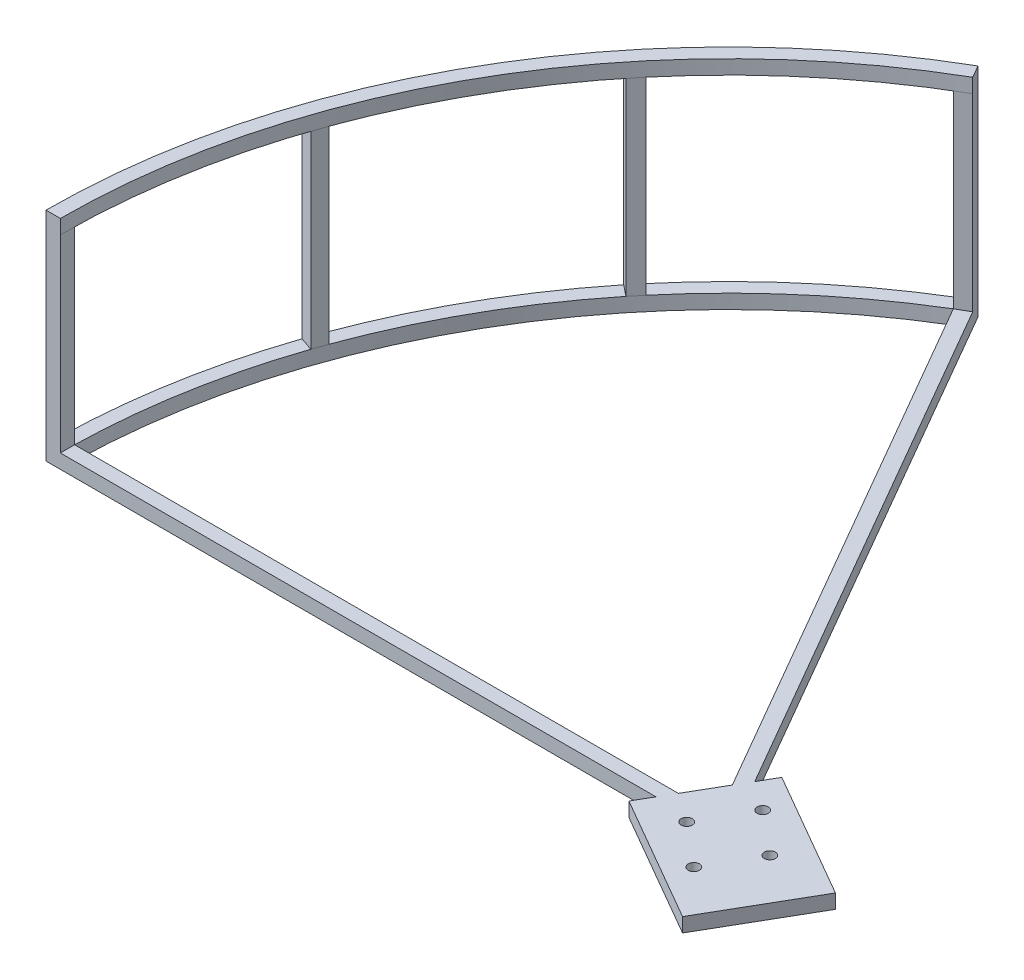
from build123d import *

# Parameters (mm, degrees)
SKETCH1_R           = 1.25
BOSS_EXTRUDE1_DEPTH = 3.175
BOSS_EXTRUDE2_DEPTH = 3.175
BOSS_EXTRUDE3_DEPTH = 42.2
BOSS_EXTRUDE4_DEPTH = 3.175


with BuildPart() as part:
    # Sketch1 → Boss-Extrude1 (new body)
    with BuildSketch(Plane(origin=(0, 90.055223859, 0), x_dir=(1, 0, 0), z_dir=(0, 1, 0))):
        Polygon((-138.728927309, 21.91435009), (-167.073938775, 38.27935009), (-179.573938775, 16.628714996), (-151.228927309, 0.263714996), align=None)
        with Locations((-169.089659252, 19.059098981)):
            Circle(SKETCH1_R, mode=Mode.SUBTRACT)
        with Locations((-162.879788078, 29.814911363)):
            Circle(SKETCH1_R, mode=Mode.SUBTRACT)
        with Locations((-153.337652818, 21.865216105)):
            Circle(SKETCH1_R, mode=Mode.SUBTRACT)
        with Locations((-159.547523992, 11.109403723)):
            Circle(SKETCH1_R, mode=Mode.SUBTRACT)
    extrude(amount=BOSS_EXTRUDE1_DEPTH)

    # Sketch2 → Boss-Extrude2 (add)
    with BuildSketch(Plane(origin=(0, 93.230223859, 0), x_dir=(1, 0, 0), z_dir=(0, 1, 0))):
        with BuildLine():
            Line((-161.213656035, 20.462157543), (-237.413656035, 152.44442908))
            ThreePointArc((-237.413656035, 152.44442908), (-293.195927572, 96.662157543), (-313.613656035, 20.462157543))
            Line((-313.613656035, 20.462157543), (-161.213656035, 20.462157543))
        make_face()
        with BuildLine():
            Line((-166.712917349, 23.637157543), (-238.558896482, 148.078043722))
            ThreePointArc((-238.558896482, 148.078043722), (-290.446296915, 95.074657543), (-310.404875616, 23.637157543))
            Line((-310.404875616, 23.637157543), (-166.712917349, 23.637157543))
        make_face(mode=Mode.SUBTRACT)
    extrude(amount=-BOSS_EXTRUDE2_DEPTH)

    # Sketch3 → Boss-Extrude3 (add)
    with BuildSketch(Plane(origin=(0, 93.230223859, 0), x_dir=(1, 0, 0), z_dir=(0, 1, 0))):
        with BuildLine():
            Line((-238.558896482, 148.078043722), (-240.204539896, 150.793275343))
            ThreePointArc((-240.204539896, 150.793275343), (-238.813489705, 151.626275405), (-237.413656035, 152.44442908))
            Line((-237.413656035, 152.44442908), (-235.809265825, 149.665543722))
            Line((-235.809265825, 149.665543722), (-238.558896482, 148.078043722))
        make_face()
        with BuildLine():
            Line((-310.404875616, 20.462157543), (-313.613656035, 20.462157543))
            ThreePointArc((-313.613656035, 20.462157543), (-313.605031003, 22.0835259), (-313.579156883, 23.704710735))
            Line((-313.579156883, 23.704710735), (-310.404875616, 23.637157543))
            Line((-310.404875616, 23.637157543), (-310.404875616, 20.462157543))
        make_face()
        with BuildLine():
            Line((-277.541611418, 113.928233857), (-280.016674298, 115.916873778))
            ThreePointArc((-280.016674298, 115.916873778), (-278.994417499, 117.175404976), (-277.958829166, 118.422989259))
            Line((-277.958829166, 118.422989259), (-275.500760757, 116.360424964))
            Line((-275.500760757, 116.360424964), (-277.541611418, 113.928233857))
        make_face()
        with BuildLine():
            Line((-302.493458116, 68.505035776), (-305.499411352, 69.527224675))
            ThreePointArc((-305.499411352, 69.527224675), (-304.969247202, 71.059489571), (-304.422811443, 72.586027386))
            Line((-304.422811443, 72.586027386), (-301.407544161, 71.488559847))
            Line((-301.407544161, 71.488559847), (-302.493458116, 68.505035776))
        make_face()
    extrude(amount=BOSS_EXTRUDE3_DEPTH)

    # Sketch4 → Boss-Extrude4 (add)
    with BuildSketch(Plane(origin=(0, 135.430223859, 0), x_dir=(1, 0, 0), z_dir=(0, 1, 0))):
        with BuildLine():
            Line((-237.413656035, 152.44442908), (-235.809265825, 149.665543722))
            ThreePointArc((-235.809265825, 149.665543722), (-290.417042213, 95.057767334), (-310.404875616, 20.462157543))
            Line((-310.404875616, 20.462157543), (-313.613656035, 20.462157543))
            ThreePointArc((-313.613656035, 20.462157543), (-293.195927572, 96.662157543), (-237.413656035, 152.44442908))
        make_face()
    extrude(amount=BOSS_EXTRUDE4_DEPTH)


solid = part.part
